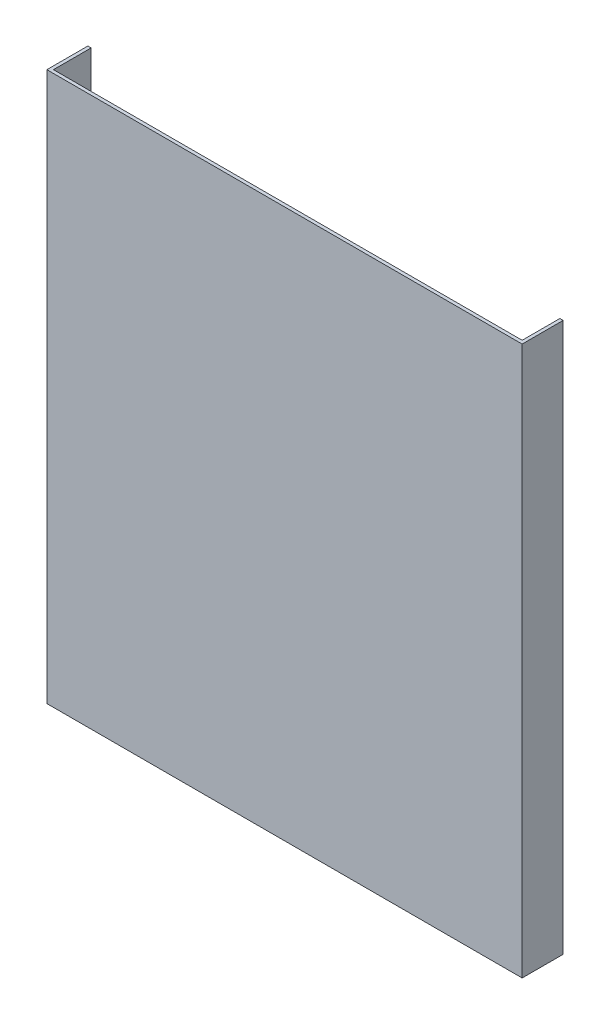
from build123d import *

# Parameters (mm, degrees)
SKETCH_1_W      = 290
SKETCH_1_H      = 335
EXTRUDE_1_DEPTH = 2
SKETCH_2_W      = 2
SKETCH_2_H      = 335
EXTRUDE_2_DEPTH = 23


with BuildPart() as part:
    # 草圖1 → 填料-伸長1 (new body)
    with BuildSketch(Plane.XY):
        with Locations((31.409495549, -105.541543027)):
            Rectangle(SKETCH_1_W, SKETCH_1_H)
    extrude(amount=EXTRUDE_1_DEPTH)

    # 草圖2 → 填料-伸長2 (add)
    with BuildSketch(Plane(origin=(0, 0, 0), x_dir=(-1, 0, 0), z_dir=(0, 0, -1))):
        with Locations((112.590504451, -105.541543027)):
            Rectangle(SKETCH_2_W, SKETCH_2_H)
        with Locations((-175.409495549, -105.541543027)):
            Rectangle(SKETCH_2_W, SKETCH_2_H)
    extrude(amount=EXTRUDE_2_DEPTH)


solid = part.part
